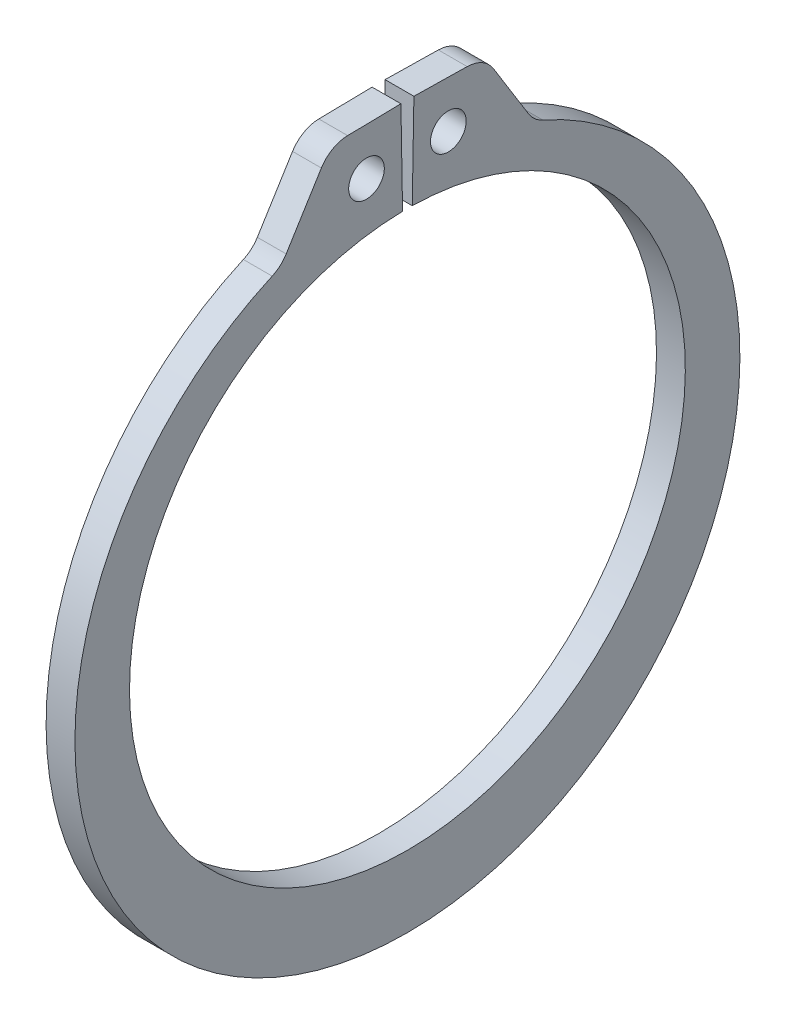
from build123d import *

# Parameters (mm, degrees)
SKETCH1_R      = 0.6604
EXTRUDE1_DEPTH = 0.5334
FILLET1_R      = 1.1684


with BuildPart() as part:
    # Sketch1 → Extrude1 (new body, symmetric)
    with BuildSketch(Plane(origin=(0, 0, 0), x_dir=(0, 0, -1), z_dir=(1, 0, 0))):
        with BuildLine():
            Line((-0.179532905, 10.28543324), (-0.240263789, 13.76470325))
            Line((-0.240263789, 13.76470325), (-2.849716296, 13.719155087))
            Line((-2.849716296, 13.719155087), (-4.681521945, 10.760524305))
            ThreePointArc((-4.681521945, 10.760524305), (0, -12.9286), (4.681521945, 10.760524305))
            Line((4.681521945, 10.760524305), (2.849716296, 13.719155087))
            Line((2.849716296, 13.719155087), (0.240263789, 13.76470325))
            Line((0.240263789, 13.76470325), (0.179532905, 10.28543324))
            ThreePointArc((0.179532905, 10.28543324), (0, -10.287), (-0.179532905, 10.28543324))
        make_face()
        with Locations((-1.514624601, 12.002294163)):
            Circle(SKETCH1_R, mode=Mode.SUBTRACT)
        with Locations((1.514624601, 12.002294163)):
            Circle(SKETCH1_R, mode=Mode.SUBTRACT)
    extrude(amount=EXTRUDE1_DEPTH, both=True)

    # Fillet1
    fillet1_edges = [part.edges().sort_by_distance(p)[0] for p in [
        (0, 13.719155087, -2.849716296),
        (0, 10.760524305, -4.681521945),
        (0, 10.760524305, 4.681521945),
        (0, 13.719155087, 2.849716296),
    ]]
    fillet(fillet1_edges, radius=FILLET1_R)


solid = part.part
